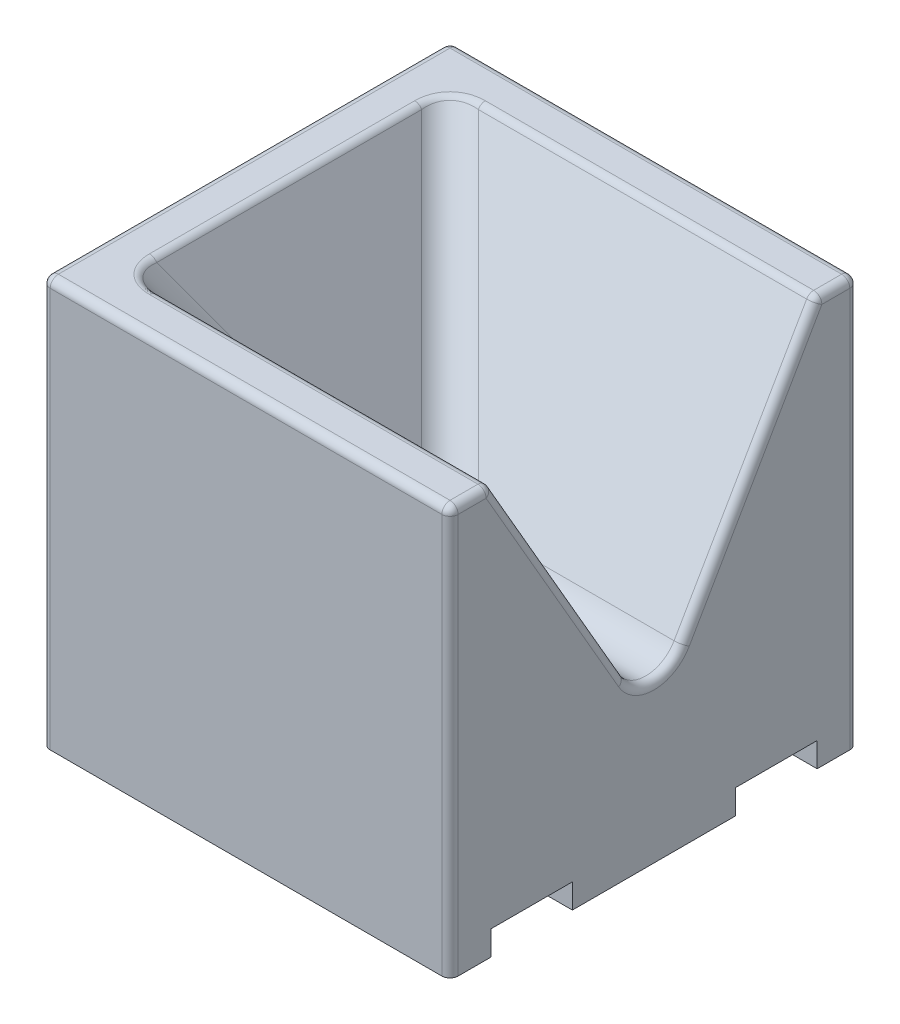
from build123d import *

# Parameters (mm, degrees)
SKETCH1_W                = 50
SKETCH1_H                = 50
BOSS_EXTRUDE1_DEPTH      = 50
CUT_EXTRUDE1_DEPTH       = 50
BOSS_EXTRUDE2_DEPTH      = 25
BOSS_EXTRUDE2_DEPTH_BACK = 25
FILLET1_R                = 4
SKETCH4_W                = 50
SKETCH4_H                = 10
CUT_EXTRUDE3_DEPTH       = 3
SKETCH5_W                = 5
SKETCH5_H                = 10
CUT_EXTRUDE4_DEPTH       = 3
LPATTERN1_COUNT          = 4
LPATTERN1_PITCH          = 11
MIRROR1_COPY_1_SKETCH_W  = 5
MIRROR1_COPY_1_SKETCH_H  = 10
MIRROR1_COPY_1_DEPTH     = 3
MIRROR1_COPY_2_SKETCH_W  = 5
MIRROR1_COPY_2_SKETCH_H  = 10
MIRROR1_COPY_2_DEPTH     = 3
MIRROR1_COPY_3_SKETCH_W  = 5
MIRROR1_COPY_3_SKETCH_H  = 10
MIRROR1_COPY_3_DEPTH     = 3
FILLET2_R                = 1


with BuildPart() as part:
    # Sketch1 → Boss-Extrude1 (new body)
    with BuildSketch(Plane(origin=(0, 0, 0), x_dir=(1, 0, 0), z_dir=(0, 1, 0))):
        with Locations((25, 0)):
            Rectangle(SKETCH1_W, SKETCH1_H)
    extrude(amount=BOSS_EXTRUDE1_DEPTH)

    # Sketch2 → Cut-Extrude1 (cut)
    with BuildSketch(Plane(origin=(0, 0, 0), x_dir=(0, 0, -1), z_dir=(1, 0, 0))):
        Polygon((20, 50), (0, 15.358983849), (-20, 50), align=None)
    extrude(amount=CUT_EXTRUDE1_DEPTH, mode=Mode.SUBTRACT)

    # Sketch3 → Boss-Extrude2 (add, two sides: drawn at the far end of the back side and taken through both)
    with BuildSketch(Plane.XY.offset(-BOSS_EXTRUDE2_DEPTH_BACK)):
        Polygon((0, 50), (5, 50), (33.867513459, 0), (0, 0), align=None)
    extrude(amount=BOSS_EXTRUDE2_DEPTH + BOSS_EXTRUDE2_DEPTH_BACK)

    # Fillet1
    fillet1_edges = [part.edges().sort_by_distance(p)[0] for p in [
        (15, 32.679491924, -10),
        (15, 32.679491924, 10),
        (37.5, 15.358983849, 0),
    ]]
    fillet(fillet1_edges, radius=FILLET1_R)

    # Sketch4 → Cut-Extrude3 (cut)
    with BuildSketch(Plane(origin=(0, 0, 0), x_dir=(1, 0, 0), z_dir=(0, 1, 0))):
        with Locations((25, -15)):
            Rectangle(SKETCH4_W, SKETCH4_H)
    cut_extrude3 = extrude(amount=CUT_EXTRUDE3_DEPTH, mode=Mode.SUBTRACT)

    # Sketch5 → Cut-Extrude4 (cut)
    with BuildSketch(Plane.XZ.offset(-3)):
        with Locations((8.5, 15)):
            Rectangle(SKETCH5_W, SKETCH5_H)
    cut_extrude4 = extrude(amount=-CUT_EXTRUDE4_DEPTH, mode=Mode.SUBTRACT)

    # LPattern1: Cut-Extrude4 ×4
    with Locations(*[(i * LPATTERN1_PITCH, 0, 0) for i in range(1, LPATTERN1_COUNT)]):
        add(cut_extrude4, mode=Mode.SUBTRACT)

    # Mirror1: Cut-Extrude3, Cut-Extrude4 across plane
    add(cut_extrude3.mirror(Plane.XY), mode=Mode.SUBTRACT)
    add(cut_extrude4.mirror(Plane.XY), mode=Mode.SUBTRACT)

    # Mirror1 copy 1 sketch → Mirror1 copy 1 (cut)
    with BuildSketch(Plane(origin=(11, 3, 0), x_dir=(1, 0, 0), z_dir=(0, -1, 0))):
        with Locations((8.5, -15)):
            Rectangle(MIRROR1_COPY_1_SKETCH_W, MIRROR1_COPY_1_SKETCH_H)
    extrude(amount=-MIRROR1_COPY_1_DEPTH, mode=Mode.SUBTRACT)

    # Mirror1 copy 2 sketch → Mirror1 copy 2 (cut)
    with BuildSketch(Plane(origin=(22, 3, 0), x_dir=(1, 0, 0), z_dir=(0, -1, 0))):
        with Locations((8.5, -15)):
            Rectangle(MIRROR1_COPY_2_SKETCH_W, MIRROR1_COPY_2_SKETCH_H)
    extrude(amount=-MIRROR1_COPY_2_DEPTH, mode=Mode.SUBTRACT)

    # Mirror1 copy 3 sketch → Mirror1 copy 3 (cut)
    with BuildSketch(Plane(origin=(33, 3, 0), x_dir=(1, 0, 0), z_dir=(0, -1, 0))):
        with Locations((8.5, -15)):
            Rectangle(MIRROR1_COPY_3_SKETCH_W, MIRROR1_COPY_3_SKETCH_H)
    extrude(amount=-MIRROR1_COPY_3_DEPTH, mode=Mode.SUBTRACT)

    # Fillet2
    fillet2_edges = [part.edges().sort_by_distance(p)[0] for p in [
        (50, 35.679491924, -11.732050808),
        (50, 19.358983849, 0),
        (50, 50, -22.5),
        (29.232050808, 50, -20),
        (5.967318437, 50, -19.032681563),
        (5, 50, 0),
        (5.967318437, 50, 19.032681563),
        (29.232050808, 50, 20),
        (50, 50, 22.5),
        (25, 50, 25),
        (0, 50, 0),
        (25, 50, -25),
        (0, 25, -25),
        (0, 25, 25),
        (50, 25, -25),
        (50, 35.679491924, 11.732050808),
        (50, 25, 25),
    ]]
    fillet(fillet2_edges, radius=FILLET2_R)


solid = part.part
